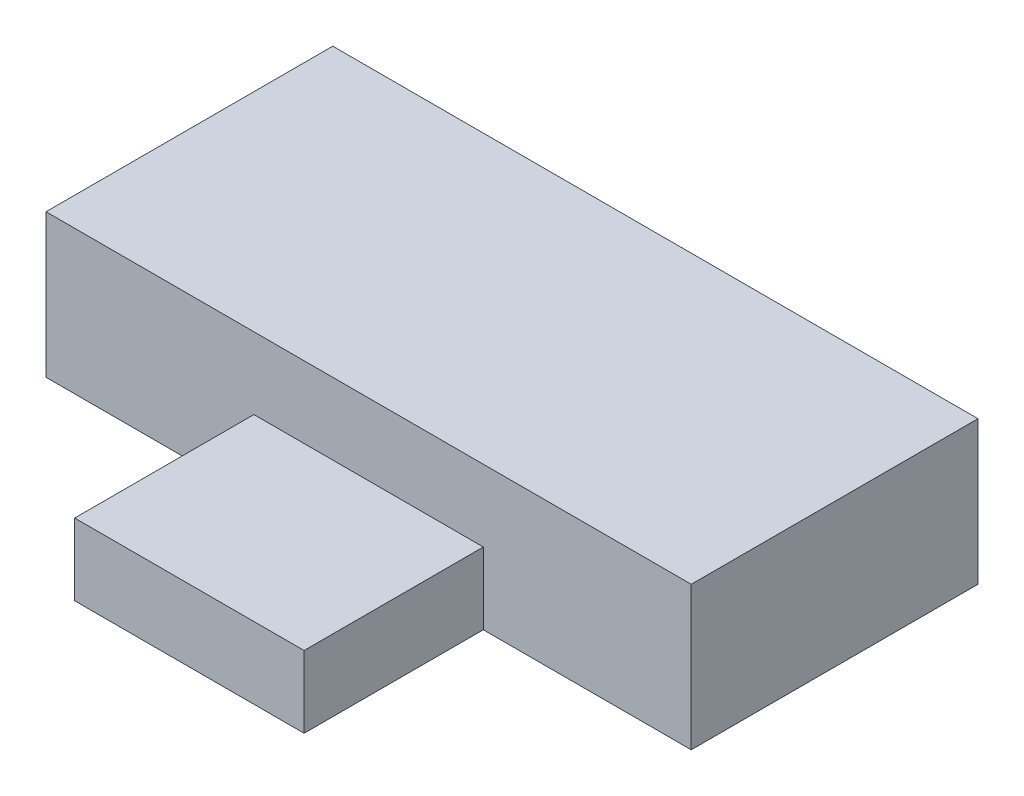
from build123d import *

# Parameters (mm, degrees)
ESQUISSE1_W        = 18
ESQUISSE1_H        = 8
BOSS_EXTRU_1_DEPTH = 4
ESQUISSE2_W        = 6.4
ESQUISSE2_H        = 2
BOSS_EXTRU_2_DEPTH = 5


with BuildPart() as part:
    # Esquisse1 → Boss.-Extru.1 (new body)
    with BuildSketch(Plane(origin=(0, 0, 0), x_dir=(1, 0, 0), z_dir=(0, 1, 0))):
        Rectangle(ESQUISSE1_W, ESQUISSE1_H)
    extrude(amount=BOSS_EXTRU_1_DEPTH)

    # Esquisse2 → Boss.-Extru.2 (add)
    with BuildSketch(Plane.XY.offset(4)):
        with Locations((0, 1)):
            Rectangle(ESQUISSE2_W, ESQUISSE2_H)
    extrude(amount=BOSS_EXTRU_2_DEPTH)


solid = part.part
